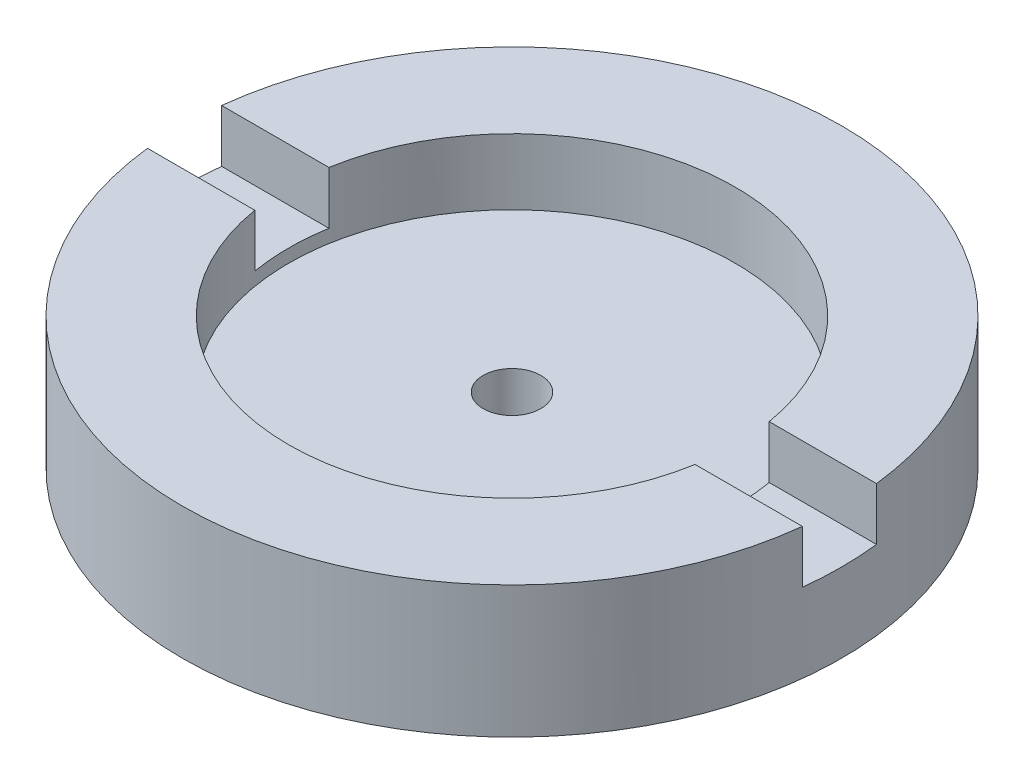
from build123d import *

# Parameters (mm, degrees)
SCHIZZO1_R                   = 20
ESTRUSIONE_ESTRUSIONE1_DEPTH = 8
SCHIZZO2_R                   = 13.55
TAGLIO_ESTRUSIONE1_DEPTH     = 4
SCHIZZO3_W                   = 56.131286276
SCHIZZO3_H                   = 4.5
TAGLIO_ESTRUSIONE2_DEPTH     = 3.2
SCHIZZO4_R                   = 1.75
TAGLIO_ESTRUSIONE3_DEPTH     = 9


with BuildPart() as part:
    # Schizzo1 → Estrusione-Estrusione1 (new body)
    with BuildSketch(Plane(origin=(0, 0, 0), x_dir=(1, 0, 0), z_dir=(0, 1, 0))):
        Circle(SCHIZZO1_R)
    extrude(amount=ESTRUSIONE_ESTRUSIONE1_DEPTH)

    # Schizzo2 → Taglio-Estrusione1 (cut)
    with BuildSketch(Plane(origin=(0, 8, 0), x_dir=(1, 0, 0), z_dir=(0, 1, 0))):
        Circle(SCHIZZO2_R)
    extrude(amount=-TAGLIO_ESTRUSIONE1_DEPTH, mode=Mode.SUBTRACT)

    # Schizzo3 → Taglio-Estrusione2 (cut)
    with BuildSketch(Plane(origin=(0, 8, 0), x_dir=(1, 0, 0), z_dir=(0, 1, 0))):
        Rectangle(SCHIZZO3_W, SCHIZZO3_H)
    extrude(amount=-TAGLIO_ESTRUSIONE2_DEPTH, mode=Mode.SUBTRACT)

    # Schizzo4 → Taglio-Estrusione3 (cut, through all)
    with BuildSketch(Plane.XZ):
        Circle(SCHIZZO4_R)
    extrude(amount=-TAGLIO_ESTRUSIONE3_DEPTH, mode=Mode.SUBTRACT)


solid = part.part
